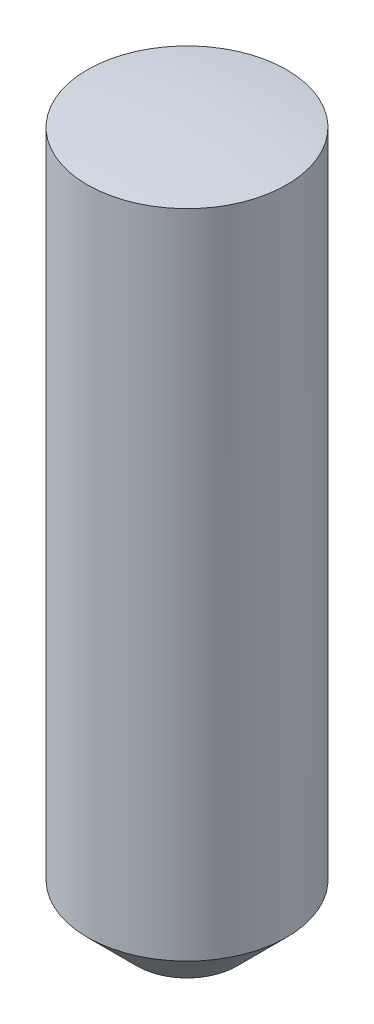
from build123d import *

# Parameters (mm, degrees)
SKETCH1_R                 = 1
BOSS_EXTRUDE_7_10MM_DEPTH = 7.1
F_0_5_X_45_DEG_SIZE       = 0.5


with BuildPart() as part:
    # Sketch1 → Boss-Extrude 7.10mm (new body)
    with BuildSketch(Plane(origin=(0, 0, 0), x_dir=(1, 0, 0), z_dir=(0, 1, 0))):
        Circle(SKETCH1_R)
    extrude(amount=-BOSS_EXTRUDE_7_10MM_DEPTH)

    # 0.5 x 45 deg
    f_0_5_x_45_deg_edges = [part.edges().sort_by_distance(p)[0] for p in [
        (-1, -7.1, 0),
    ]]
    chamfer(f_0_5_x_45_deg_edges, length=F_0_5_X_45_DEG_SIZE)

    # Sketch2 → SR8 (revolve, cut)
    with BuildSketch(Plane.XY):
        with BuildLine():
            Line((0, 2), (-2, 2))
            Line((-2, 2), (-2, -0.254033308))
            ThreePointArc((-2, -0.254033308), (-1.00803434, -0.06376243), (0, 0))
            Line((0, 0), (0, 2))
        make_face()
    revolve(axis=Axis((0, 0, 0), (0, 1, 0)), mode=Mode.SUBTRACT)


solid = part.part
